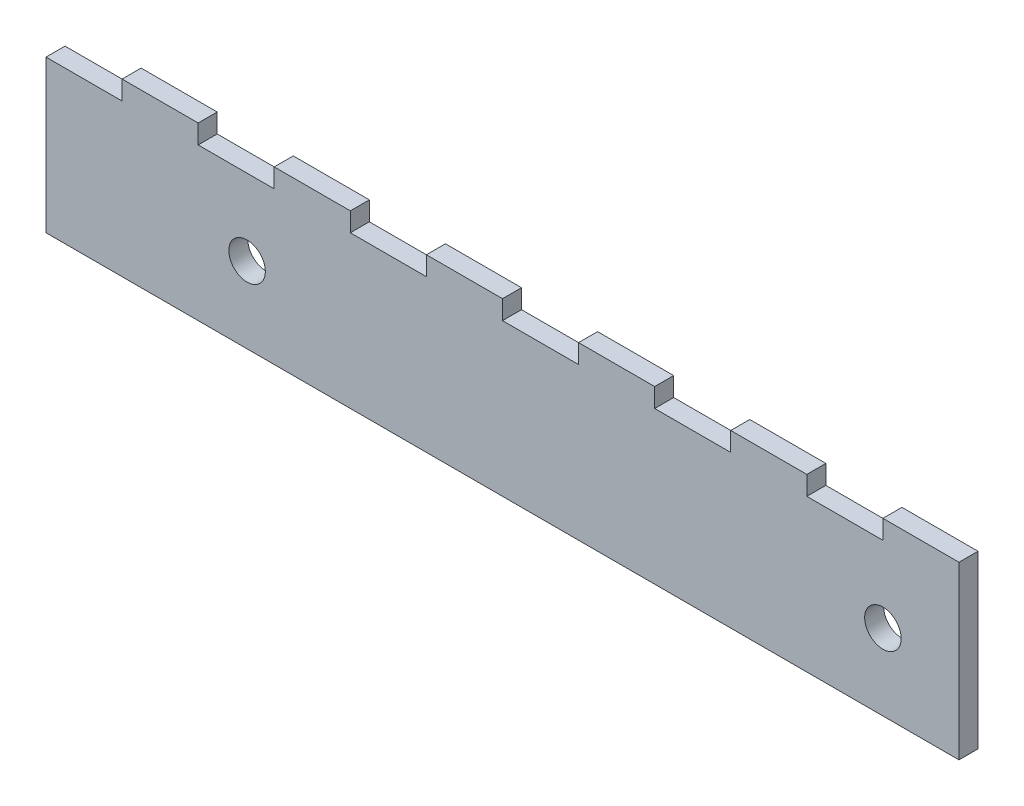
from build123d import *

# Parameters (mm, degrees)
SKETCH1_W           = 152.4
SKETCH1_H           = 25.4
SKETCH1_R           = 3.048
BOSS_EXTRUDE1_DEPTH = 3.175
SKETCH3_W           = 12.7
SKETCH3_H           = 3.175
BOSS_EXTRUDE3_DEPTH = 3.175


with BuildPart() as part:
    # Sketch1 → Boss-Extrude1 (new body)
    with BuildSketch(Plane.XY):
        with Locations((76.2, 12.7)):
            Rectangle(SKETCH1_W, SKETCH1_H)
        with Locations((139.7, 12.7)):
            Circle(SKETCH1_R, mode=Mode.SUBTRACT)
        with Locations((33.56356, 12.7)):
            Circle(SKETCH1_R, mode=Mode.SUBTRACT)
    extrude(amount=BOSS_EXTRUDE1_DEPTH)

    # Sketch3 → Boss-Extrude3 (add)
    with BuildSketch(Plane(origin=(0, 25.4, 0), x_dir=(1, 0, 0), z_dir=(0, 1, 0))):
        with Locations((146.05, -1.5875)):
            Rectangle(SKETCH3_W, SKETCH3_H)
        with Locations((120.65, -1.5875)):
            Rectangle(SKETCH3_W, SKETCH3_H)
        with Locations((95.25, -1.5875)):
            Rectangle(SKETCH3_W, SKETCH3_H)
        with Locations((69.85, -1.5875)):
            Rectangle(SKETCH3_W, SKETCH3_H)
        with Locations((44.45, -1.5875)):
            Rectangle(SKETCH3_W, SKETCH3_H)
        with Locations((19.05, -1.5875)):
            Rectangle(SKETCH3_W, SKETCH3_H)
    extrude(amount=BOSS_EXTRUDE3_DEPTH)


solid = part.part
